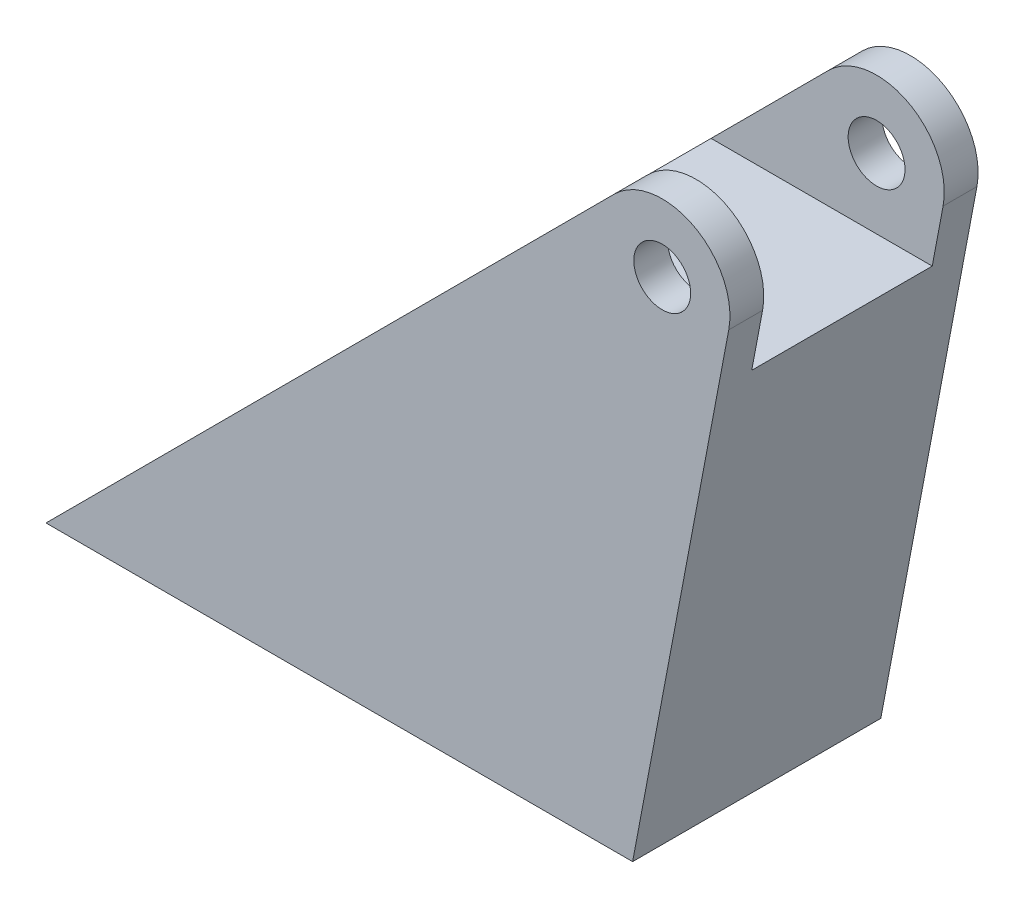
from build123d import *

# Parameters (mm, degrees)
SKETCH1_R           = 4
BOSS_EXTRUDE1_DEPTH = 4.7625
SKETCH2_R           = 4
BOSS_EXTRUDE2_DEPTH = 25.4
BOSS_EXTRUDE3_START = 30.1625
SKETCH1_2_R         = 4
BOSS_EXTRUDE3_DEPTH = 4.7625
SKETCH4_W           = 82.55
SKETCH4_H           = 34.925
CUT_EXTRUDE1_DEPTH  = 19.05
SKETCH5_R           = 3.2639
CUT_EXTRUDE2_DEPTH  = 31.75


with BuildPart() as part:
    # Sketch1 → Boss-Extrude1 (new body)
    with BuildSketch(Plane.XY):
        with BuildLine():
            Line((0, 0), (0, 19.05))
            Line((0, 19.05), (13.525460699, 90.621522374))
            ThreePointArc((13.525460699, 90.621522374), (8.613422955, 100.813245135), (-2.573048888, 99.121448653))
            Line((-2.573048888, 99.121448653), (-82.55, 19.05))
            Line((-82.55, 19.05), (-82.55, 0))
            Line((-82.55, 0), (0, 0))
        make_face()
        with Locations((4.166118695, 92.390234401)):
            Circle(SKETCH1_R, mode=Mode.SUBTRACT)
        with Locations((-9.525, 9.525)):
            Circle(SKETCH1_R, mode=Mode.SUBTRACT)
        with Locations((-73.025, 9.525)):
            Circle(SKETCH1_R, mode=Mode.SUBTRACT)
    extrude(amount=BOSS_EXTRUDE1_DEPTH)

    # Sketch2 → Boss-Extrude2 (add)
    with BuildSketch(Plane.XY.offset(4.7625)):
        Polygon((-19.124940493, 82.55), (12.000118566, 82.55), (0, 19.05), (0, 0), (-82.55, 0), (-82.55, 19.05), align=None)
        with Locations((-73.025, 9.525)):
            Circle(SKETCH2_R, mode=Mode.SUBTRACT)
        with Locations((-9.525, 9.525)):
            Circle(SKETCH2_R, mode=Mode.SUBTRACT)
    extrude(amount=BOSS_EXTRUDE2_DEPTH)

    # Sketch1_2 → Boss-Extrude3 (add)
    with BuildSketch(Plane.XY.offset(BOSS_EXTRUDE3_START)):
        with BuildLine():
            Line((0, 0), (0, 19.05))
            Line((0, 19.05), (13.525460699, 90.621522374))
            ThreePointArc((13.525460699, 90.621522374), (8.613422955, 100.813245135), (-2.573048888, 99.121448653))
            Line((-2.573048888, 99.121448653), (-82.55, 19.05))
            Line((-82.55, 19.05), (-82.55, 0))
            Line((-82.55, 0), (0, 0))
        make_face()
        with Locations((4.166118695, 92.390234401)):
            Circle(SKETCH1_2_R, mode=Mode.SUBTRACT)
        with Locations((-9.525, 9.525)):
            Circle(SKETCH1_2_R, mode=Mode.SUBTRACT)
        with Locations((-73.025, 9.525)):
            Circle(SKETCH1_2_R, mode=Mode.SUBTRACT)
    extrude(amount=BOSS_EXTRUDE3_DEPTH)

    # Sketch4 → Cut-Extrude1 (cut)
    with BuildSketch(Plane.XZ):
        with Locations((-41.275, 17.4625)):
            Rectangle(SKETCH4_W, SKETCH4_H)
    extrude(amount=-CUT_EXTRUDE1_DEPTH, mode=Mode.SUBTRACT)

    # Sketch5 → Cut-Extrude2 (cut)
    with BuildSketch(Plane.XZ.offset(-19.05)):
        with Locations((-9.525, 9.525)):
            Circle(SKETCH5_R)
        with Locations((-73.025, 9.525)):
            Circle(SKETCH5_R)
        with Locations((-73.025, 28.575)):
            Circle(SKETCH5_R)
        with Locations((-9.525, 28.575)):
            Circle(SKETCH5_R)
        with Locations((-73.025, 19.05)):
            Circle(SKETCH5_R)
        with Locations((-9.525, 19.05)):
            Circle(SKETCH5_R)
    extrude(amount=-CUT_EXTRUDE2_DEPTH, mode=Mode.SUBTRACT)


solid = part.part
